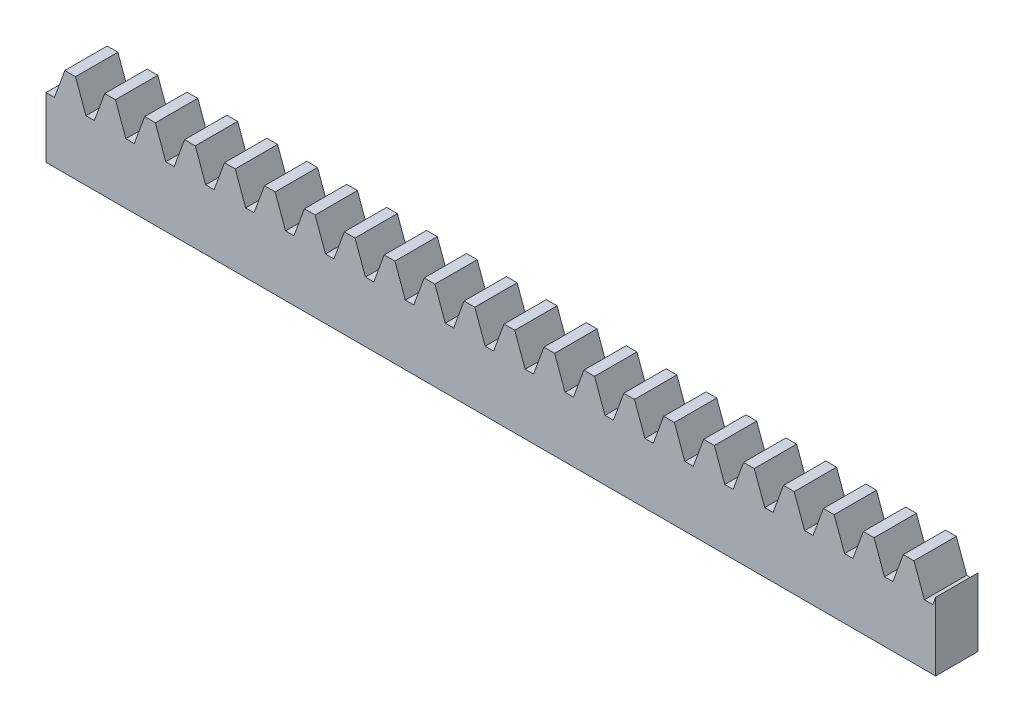
from build123d import *

# Parameters (mm, degrees)
BOSS_EXTRUDE1_DEPTH = 10
SKETCH3_W           = 210
SKETCH3_H           = 10
BOSS_EXTRUDE2_DEPTH = 10
SKETCH4_R           = 1
CUT_EXTRUDE1_DEPTH  = 10


with BuildPart() as part:
    # Sketch1 → Boss-Extrude1 (new body)
    with BuildSketch(Plane(origin=(0, 0, 0), x_dir=(-1, 0, 0), z_dir=(0, 0, -1))):
        Polygon((-105, -1.902946103), (-105, -8), (105, -8), (105, -3.75), (103.017387777, -3.75), (100.560588695, 3), (98.032021121, 3), (95.575222039, -3.75), (93.592609816, -3.75), (91.135810735, 3), (88.60724316, 3), (86.150444078, -3.75), (84.167831855, -3.75), (81.711032774, 3), (79.182465199, 3), (76.725666118, -3.75), (74.743053894, -3.75), (72.286254813, 3), (69.757687238, 3), (67.300888157, -3.75), (65.318275934, -3.75), (62.861476852, 3), (60.332909277, 3), (57.876110196, -3.75), (55.893497973, -3.75), (53.436698891, 3), (50.908131317, 3), (48.451332235, -3.75), (46.468720012, -3.75), (44.011920931, 3), (41.483353356, 3), (39.026554275, -3.75), (37.043942051, -3.75), (34.58714297, 3), (32.058575395, 3), (29.601776314, -3.75), (27.61916409, -3.75), (25.162365009, 3), (22.633797434, 3), (20.176998353, -3.75), (18.19438613, -3.75), (15.737587048, 3), (13.209019474, 3), (10.752220392, -3.75), (8.769608169, -3.75), (6.312809088, 3), (3.784241513, 3), (1.327442432, -3.75), (-0.655169792, -3.75), (-3.111968873, 3), (-5.640536448, 3), (-8.097335529, -3.75), (-10.079947753, -3.75), (-12.536746834, 3), (-15.065314409, 3), (-17.52211349, -3.75), (-19.504725713, -3.75), (-21.961524795, 3), (-24.490092369, 3), (-26.946891451, -3.75), (-28.929503674, -3.75), (-31.386302755, 3), (-33.91487033, 3), (-36.371669412, -3.75), (-38.354281635, -3.75), (-40.811080716, 3), (-43.339648291, 3), (-45.796447372, -3.75), (-47.779059596, -3.75), (-50.235858677, 3), (-52.764426252, 3), (-55.221225333, -3.75), (-57.203837556, -3.75), (-59.660636638, 3), (-62.189204213, 3), (-64.646003294, -3.75), (-66.628615517, -3.75), (-69.085414599, 3), (-71.613982173, 3), (-74.070781255, -3.75), (-76.053393478, -3.75), (-78.510192559, 3), (-81.038760134, 3), (-83.495559215, -3.75), (-85.478171439, -3.75), (-87.93497052, 3), (-90.463538095, 3), (-92.920337176, -3.75), (-94.9029494, -3.75), (-97.359748481, 3), (-99.888316056, 3), (-102.345115137, -3.75), (-104.32772736, -3.75), align=None)
    extrude(amount=-BOSS_EXTRUDE1_DEPTH)

    # Sketch3 → Boss-Extrude2 (add)
    with BuildSketch(Plane.XZ.offset(8)):
        with Locations((0, 5)):
            Rectangle(SKETCH3_W, SKETCH3_H)
    extrude(amount=BOSS_EXTRUDE2_DEPTH)

    # Sketch4 → Cut-Extrude1 (cut)
    with BuildSketch(Plane.ZY.offset(105)):
        with Locations((5, -10.9)):
            Circle(SKETCH4_R)
    extrude(amount=-CUT_EXTRUDE1_DEPTH, mode=Mode.SUBTRACT)


solid = part.part
